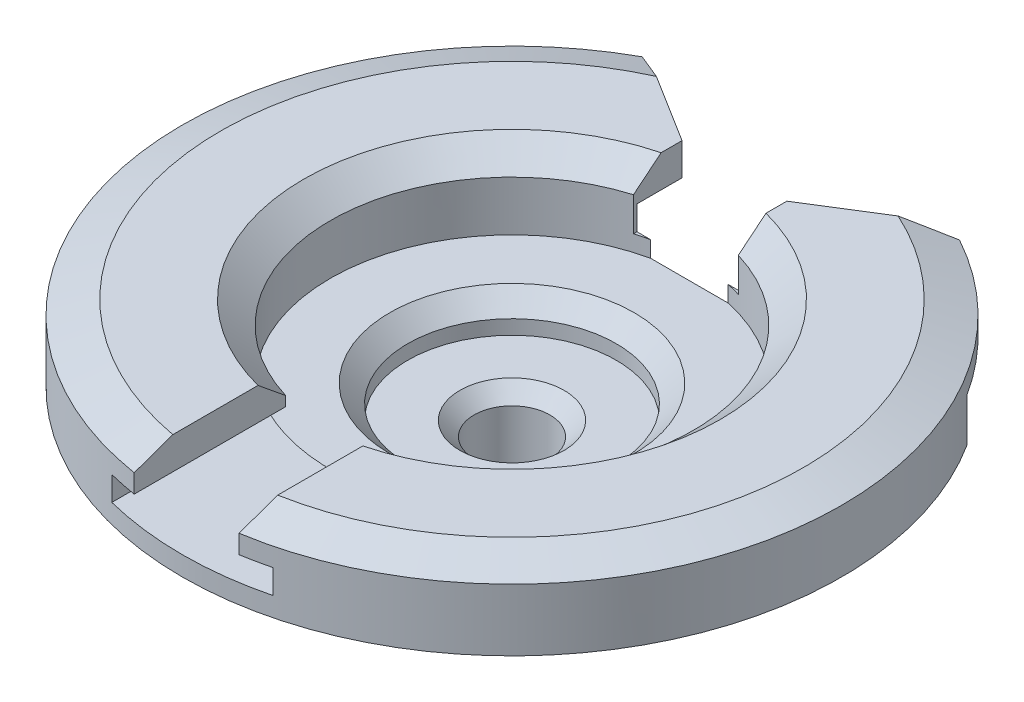
from build123d import *

# Parameters (mm, degrees)
SKETCH1_R           = 1.25
BOSS_EXTRUDE1_DEPTH = 0.58
SKETCH2_R           = 2.043
BOSS_EXTRUDE2_DEPTH = 0.47
CUT_EXTRUDE1_REACH  = 3.45
CUT_EXTRUDE1_START  = 0.4
SKETCH3_R           = 0.6465
CUT_EXTRUDE2_REACH  = 3.65
CUT_EXTRUDE2_START  = 0.6
SKETCH4_R           = 1.126
CUT_EXTRUDE3_REACH  = 3.05
SKETCH5_R           = 0.235
CHAMFER1_SIZE       = 0.05
CHAMFER2_SIZE       = 0.088
CHAMFER3_SIZE       = 0.111
CHAMFER4_SIZE       = 0.165
CHAMFER4_SIZE2      = 0.14
CHAMFER5_SIZE       = 0.085
CHAMFER5_SIZE2      = 0.236
CUT_EXTRUDE4_REACH  = 4.043
CUT_EXTRUDE5_REACH  = 2.45
SKETCH8_W           = 0.48
SKETCH8_H           = 1.704544177
SKETCH9_W           = 0.65
SKETCH9_H           = 1.293267811
CUT_EXTRUDE6_DEPTH  = 0.35
SKETCH10_W          = 5.093485532
SKETCH10_H          = 1.197948417
CUT_EXTRUDE7_DEPTH  = 0.85
CUT_EXTRUDE8_DEPTH  = 2.05


with BuildPart() as part:
    # Sketch1 → Boss-Extrude1 (new body)
    with BuildSketch(Plane(origin=(0, 0, 0), x_dir=(1, 0, 0), z_dir=(0, 1, 0))):
        Circle(SKETCH1_R)
    extrude(amount=BOSS_EXTRUDE1_DEPTH)

    # Sketch2 → Boss-Extrude2 (add)
    with BuildSketch(Plane(origin=(0, 0.58, 0), x_dir=(1, 0, 0), z_dir=(0, 1, 0))):
        Circle(SKETCH2_R)
    extrude(amount=BOSS_EXTRUDE2_DEPTH)

    # Sketch3 → Cut-Extrude1 (cut, up to next)
    with BuildSketch(Plane(origin=(0, 0, 0), x_dir=(1, 0, 0), z_dir=(0, 1, 0)).offset(CUT_EXTRUDE1_START), mode=Mode.PRIVATE) as cut_extrude1_sk1:
        Circle(SKETCH3_R)
    cut_extrude1_tool1 = extrude(cut_extrude1_sk1.sketch, amount=CUT_EXTRUDE1_REACH, mode=Mode.PRIVATE) & part.part
    add(cut_extrude1_tool1.solids().sort_by_distance((0, 0.4, 0))[0], mode=Mode.SUBTRACT)

    # Sketch4 → Cut-Extrude2 (cut, up to next)
    with BuildSketch(Plane(origin=(0, 0, 0), x_dir=(1, 0, 0), z_dir=(0, 1, 0)).offset(CUT_EXTRUDE2_START), mode=Mode.PRIVATE) as cut_extrude2_sk1:
        Circle(SKETCH4_R)
    cut_extrude2_tool1 = extrude(cut_extrude2_sk1.sketch, amount=CUT_EXTRUDE2_REACH, mode=Mode.PRIVATE) & part.part
    add(cut_extrude2_tool1.solids().sort_by_distance((0, 0.6, 0))[0], mode=Mode.SUBTRACT)

    # Sketch5 → Cut-Extrude3 (cut, up to next)
    with BuildSketch(Plane(origin=(0, 0, 0), x_dir=(1, 0, 0), z_dir=(0, 1, 0)), mode=Mode.PRIVATE) as cut_extrude3_sk1:
        Circle(SKETCH5_R)
    cut_extrude3_tool1 = extrude(cut_extrude3_sk1.sketch, amount=CUT_EXTRUDE3_REACH, mode=Mode.PRIVATE) & part.part
    add(cut_extrude3_tool1.solids().sort_by_distance((0, 0, 0))[0], mode=Mode.SUBTRACT)

    # Chamfer1
    chamfer1_edges = [part.edges().sort_by_distance(p)[0] for p in [
        (-1.25, 0, 0),
    ]]
    chamfer(chamfer1_edges, length=CHAMFER1_SIZE)

    # Chamfer2
    chamfer2_edges = [part.edges().sort_by_distance(p)[0] for p in [
        (-0.235, 0.4, 0),
    ]]
    chamfer(chamfer2_edges, length=CHAMFER2_SIZE)

    # Chamfer3
    chamfer3_edges = [part.edges().sort_by_distance(p)[0] for p in [
        (-0.6465, 0.6, 0),
    ]]
    chamfer(chamfer3_edges, length=CHAMFER3_SIZE)

    # Chamfer4
    chamfer4_edges = [part.edges().sort_by_distance(p)[0] for p in [
        (-1.126, 1.05, 0),
    ]]
    chamfer4_side = [part.faces().sort_by_distance(p)[0] for p in [
        (-1.985215234, 1.05, 0),
    ]]
    chamfer(chamfer4_edges, length=CHAMFER4_SIZE, length2=CHAMFER4_SIZE2, reference=chamfer4_side[0])

    # Chamfer5
    chamfer5_edges = [part.edges().sort_by_distance(p)[0] for p in [
        (-2.043, 1.05, 0),
    ]]
    chamfer5_side = [part.faces().sort_by_distance(p)[0] for p in [
        (-2.043, 0.815, 0),
    ]]
    chamfer(chamfer5_edges, length=CHAMFER5_SIZE, length2=CHAMFER5_SIZE2, reference=chamfer5_side[0])

    # Sketch7 → Cut-Extrude4 (cut, up to next)
    with BuildSketch(Plane.XY, mode=Mode.PRIVATE) as cut_extrude4_sk1:
        Polygon((-0.325, 1.220261845), (-0.325, 0.85), (-0.5, 0.85), (-0.5, 0.7), (0.5, 0.7), (0.5, 0.85), (0.325, 0.85), (0.325, 1.220261845), align=None)
    cut_extrude4_tool1 = extrude(cut_extrude4_sk1.sketch, amount=CUT_EXTRUDE4_REACH, mode=Mode.PRIVATE) & part.part
    add(cut_extrude4_tool1.solids().sort_by_distance((0, 0.935252, 0))[0], mode=Mode.SUBTRACT)

    # Sketch8 → Cut-Extrude5 (cut, up to next)
    with BuildSketch(Plane(origin=(0, 0.6, 0), x_dir=(1, 0, 0), z_dir=(0, 1, 0)), mode=Mode.PRIVATE) as cut_extrude5_sk1:
        with Locations((0, 1.786577137)):
            Rectangle(SKETCH8_W, SKETCH8_H)
    cut_extrude5_tool1 = extrude(cut_extrude5_sk1.sketch, amount=CUT_EXTRUDE5_REACH, mode=Mode.PRIVATE) & part.part
    add(cut_extrude5_tool1.solids().sort_by_distance((0, 0.6, -1.786577))[0], mode=Mode.SUBTRACT)

    # Sketch9 → Cut-Extrude6 (cut)
    with BuildSketch(Plane(origin=(0, 0.7, 0), x_dir=(1, 0, 0), z_dir=(0, 1, 0))):
        with Locations((0, 1.604554183)):
            Rectangle(SKETCH9_W, SKETCH9_H)
    extrude(amount=CUT_EXTRUDE6_DEPTH, mode=Mode.SUBTRACT)

    # Sketch10 → Cut-Extrude7 (cut)
    with BuildSketch(Plane(origin=(0, 0, 0), x_dir=(1, 0, 0), z_dir=(0, 1, 0))):
        with Locations((-0.004402354, 1.698974209)):
            Rectangle(SKETCH10_W, SKETCH10_H)
    extrude(amount=CUT_EXTRUDE7_DEPTH, mode=Mode.SUBTRACT)

    # Sketch11 → Cut-Extrude8 (cut, through all)
    with BuildSketch(Plane(origin=(0, 0, 0), x_dir=(1, 0, 0), z_dir=(0, 1, 0))):
        Polygon((-1.831685312, 2.320481475), (0, 1.175917461), (1.831685312, 2.320481475), align=None)
    extrude(amount=CUT_EXTRUDE8_DEPTH, mode=Mode.SUBTRACT)


solid = part.part
